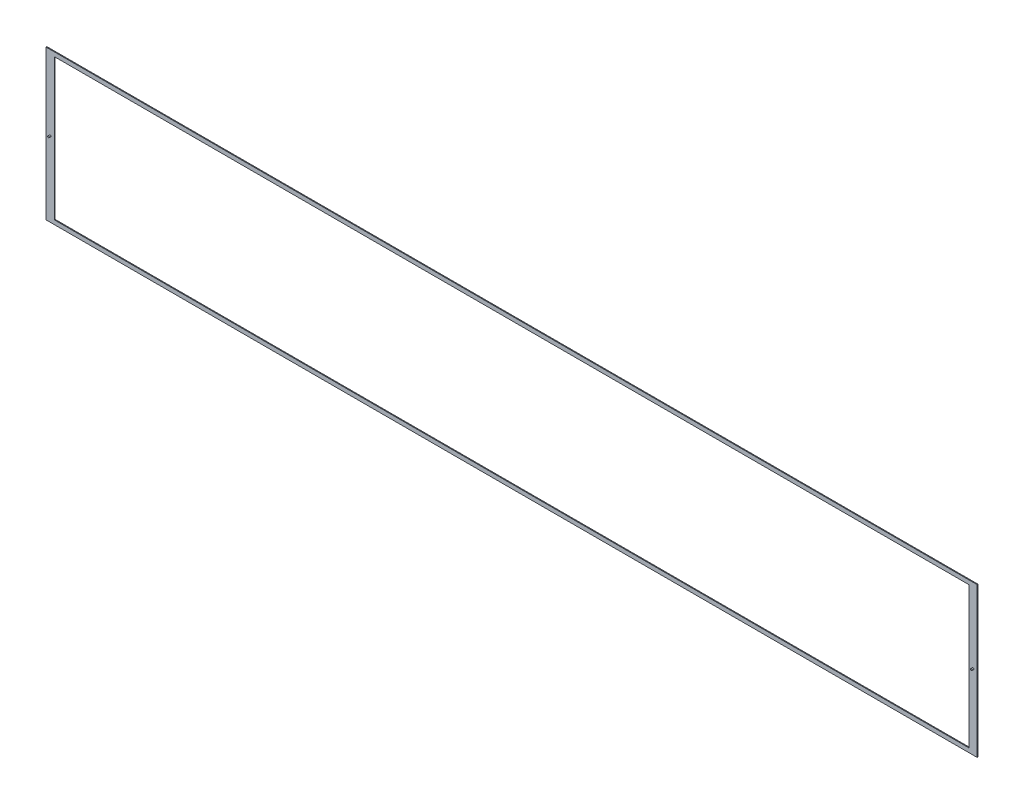
from build123d import *

# Parameters (mm, degrees)
SKETCH1_W           = 1120
SKETCH1_H           = 180
SKETCH1_W_2         = 1100
SKETCH1_H_2         = 170
BOSS_EXTRUDE1_DEPTH = 1
SKETCH2_R           = 1
BOSS_EXTRUDE2_DEPTH = 2


with BuildPart() as part:
    # Sketch1 → Boss-Extrude1 (new body)
    with BuildSketch(Plane.XY):
        Rectangle(SKETCH1_W, SKETCH1_H)
        Rectangle(SKETCH1_W_2, SKETCH1_H_2, mode=Mode.SUBTRACT)
    extrude(amount=BOSS_EXTRUDE1_DEPTH)

    # Sketch2 → Boss-Extrude2 (add)
    with BuildSketch(Plane.XY.offset(1)):
        with Locations((-555, 0)):
            Circle(SKETCH2_R)
    boss_extrude2 = extrude(amount=BOSS_EXTRUDE2_DEPTH)

    # Mirror1: Boss-Extrude2 across plane
    add(boss_extrude2.mirror(Plane(origin=(0, 0, 0), x_dir=(0, 0, 1), z_dir=(1, 0, 0))))


solid = part.part
